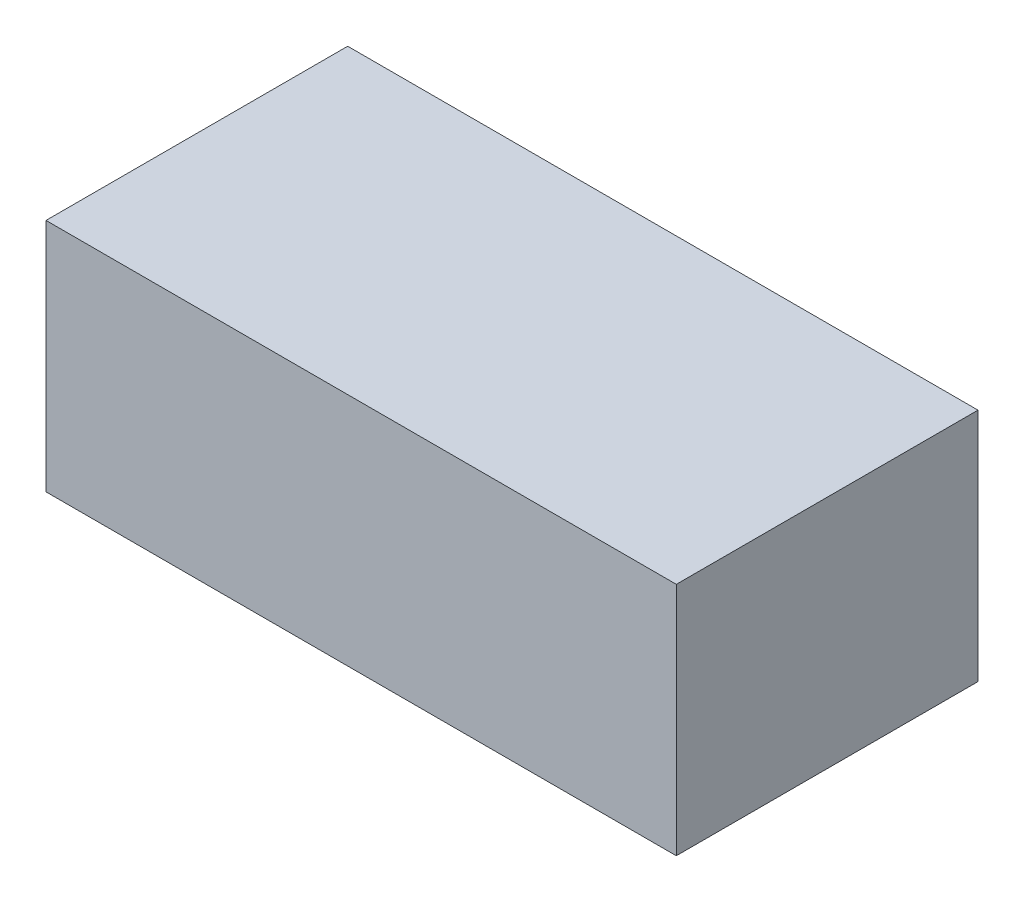
from build123d import *

# Parameters (mm, degrees)
SKETCH1_W           = 74
SKETCH1_H           = 35.42
BOSS_EXTRUDE1_DEPTH = 27.6


with BuildPart() as part:
    # Sketch1 → Boss-Extrude1 (new body)
    with BuildSketch(Plane(origin=(0, 0, 0), x_dir=(1, 0, 0), z_dir=(0, 1, 0))):
        Rectangle(SKETCH1_W, SKETCH1_H)
    extrude(amount=BOSS_EXTRUDE1_DEPTH)


solid = part.part
